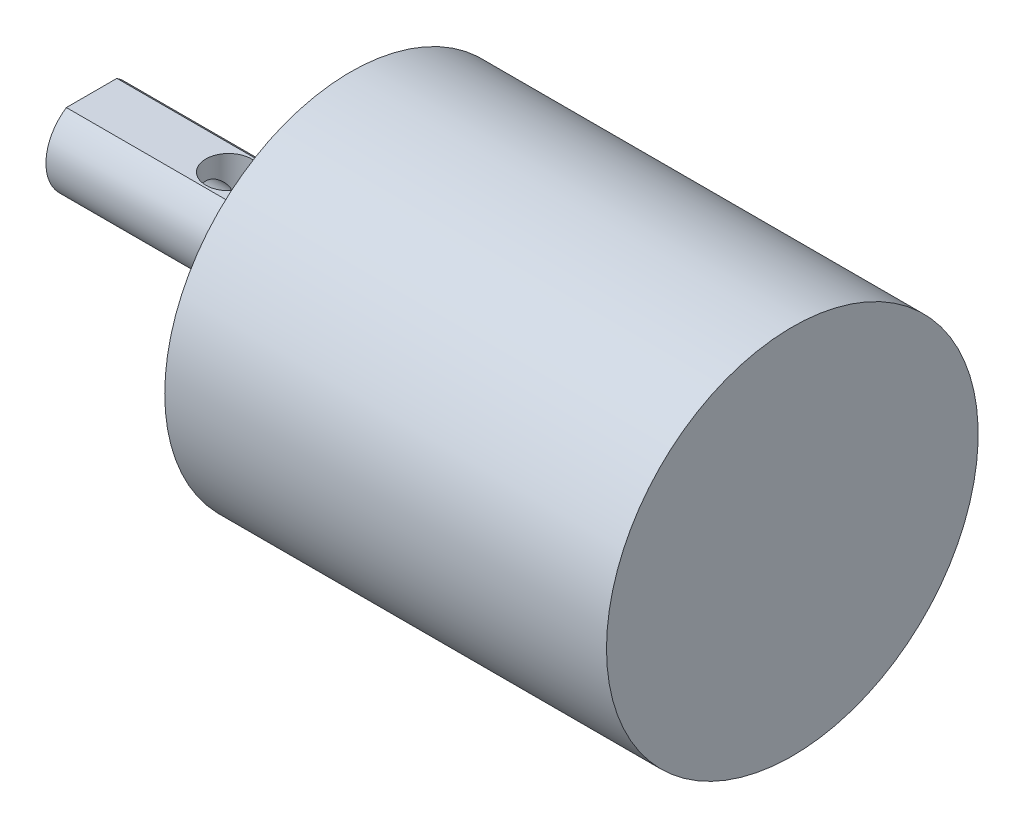
from build123d import *

# Parameters (mm, degrees)
CUT_EXTRUDE_3_DEPTH    = 11.5
HOLE_WIZARD_M3_1_D     = 2.5
HOLE_WIZARD_M3_1_DEPTH = 8
HOLE_WIZARD_M3_1_TIP   = 0.751075774
SKETCH_12_R            = 1.5
CUT_EXTRUDE_4_DEPTH    = 11.5
HOLE_WIZARD_M3_2_D     = 2.5
HOLE_WIZARD_M3_2_DEPTH = 4
HOLE_WIZARD_M3_2_TIP   = 0.751075774
EXTRUDE_1_DEPTH        = 0.5


with BuildPart() as part:
    # 草图1 → 旋转1 (revolve)
    with BuildSketch(Plane(origin=(0, 0, 0), x_dir=(1, 0, 0), z_dir=(0, 1, 0))):
        Polygon((0, 0), (-29, 0), (-29, 5.7), (-31.6, 5.7), (-31.6, 9.2), (-46, 9.2), (-46, 12.2), (0, 12.2), align=None)
    revolve(axis=Axis((-46, 0, -12.2), (1, 0, 0)))

    # 草图9 → 切除-拉伸3 (cut)
    with BuildSketch(Plane.ZY.offset(46)):
        with BuildLine():
            Line((-12.2, 2.5), (-10.541687605, 2.5))
            ThreePointArc((-10.541687605, 2.5), (-12.2, 3), (-13.858312395, 2.5))
            Line((-13.858312395, 2.5), (-12.2, 2.5))
        make_face()
    extrude(amount=-CUT_EXTRUDE_3_DEPTH, mode=Mode.SUBTRACT)

    # M3 螺纹孔1
    with Locations(Plane.ZY.offset(46)):
        with Locations((-12.2, 0)):
            Hole(HOLE_WIZARD_M3_1_D / 2, depth=HOLE_WIZARD_M3_1_DEPTH)
            with Locations((0, 0, -(HOLE_WIZARD_M3_1_DEPTH + HOLE_WIZARD_M3_1_TIP / 2))):  # 118° drill point
                Cone(0, HOLE_WIZARD_M3_1_D / 2, HOLE_WIZARD_M3_1_TIP, mode=Mode.SUBTRACT)

    # 草图12 → 切除-拉伸4 (cut)
    with BuildSketch(Plane(origin=(0, 2.5, 0), x_dir=(1, 0, 0), z_dir=(0, 1, 0))):
        with Locations((-37, 12.2)):
            Circle(SKETCH_12_R)
    extrude(amount=-CUT_EXTRUDE_4_DEPTH, mode=Mode.SUBTRACT)

    # M3 螺纹孔2
    with Locations(Plane.ZY.offset(29)):
        with Locations((-12.2, 9.5), (-20.427241336, -4.75), (-3.972758664, -4.75)):
            Hole(HOLE_WIZARD_M3_2_D / 2, depth=HOLE_WIZARD_M3_2_DEPTH)
            with Locations((0, 0, -(HOLE_WIZARD_M3_2_DEPTH + HOLE_WIZARD_M3_2_TIP / 2))):  # 118° drill point
                Cone(0, HOLE_WIZARD_M3_2_D / 2, HOLE_WIZARD_M3_2_TIP, mode=Mode.SUBTRACT)

    # 草图16 → 凸台-拉伸1 (add)
    with BuildSketch(Plane.ZY.offset(31.6)):
        with BuildLine():
            Line((-9.601923789, -1.5), (-12.2, -6))
            ThreePointArc((-12.2, -6), (-8.525765386, 4.74341649), (-18.009475019, -1.5))
            Line((-18.009475019, -1.5), (-14.69206472, 1.670213589))
            ThreePointArc((-14.69206472, 1.670213589), (-10.614007201, 2.546493048), (-9.601923789, -1.5))
        make_face()
    extrude(amount=EXTRUDE_1_DEPTH)


solid = part.part
